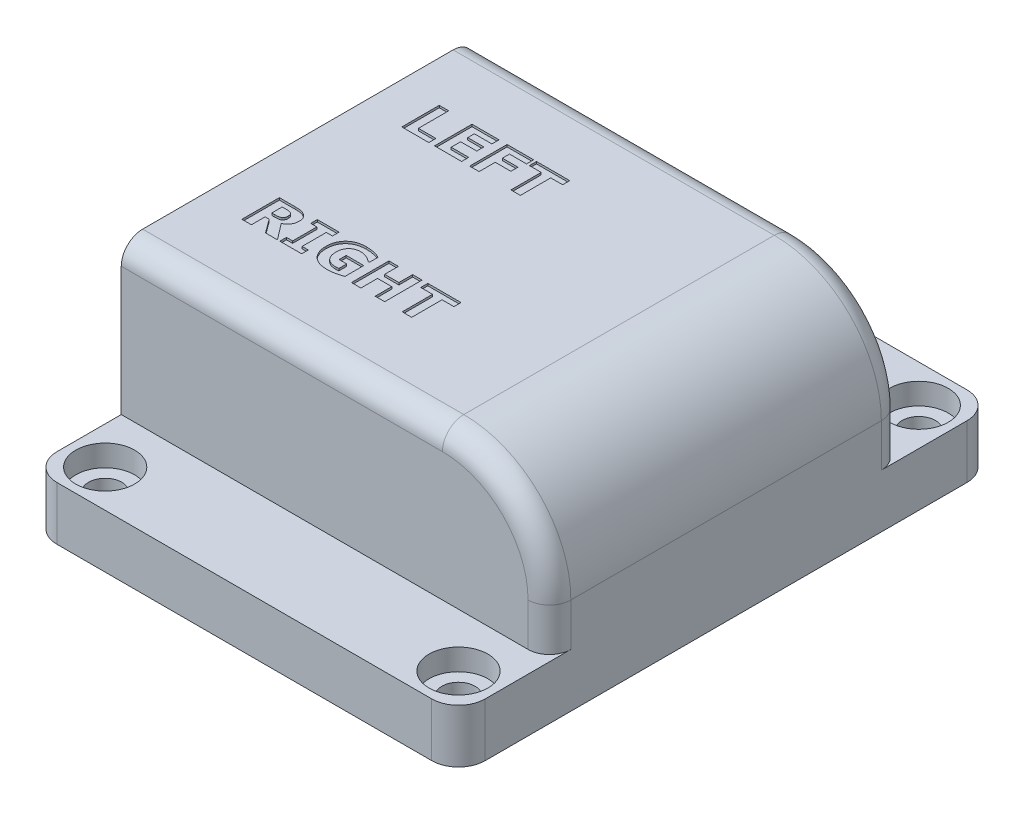
from build123d import *

# Parameters (mm, degrees)
SKETCH1_W               = 40
SKETCH1_H               = 50
BOSS_EXTRUDE1_DEPTH     = 5
SKETCH2_W               = 40
SKETCH2_H               = 33
BOSS_EXTRUDE2_DEPTH     = 14
CUT_EXTRUDE2_DEPTH      = 23
SKETCH6_W               = 14
SKETCH6_H               = 30
CUT_EXTRUDE3_DEPTH      = 17.25
FILLET1_R               = 10
SKETCH7_W               = 5
SKETCH7_H               = 5
CUT_EXTRUDE4_DEPTH      = 0.6
SKETCH8_R               = 1.55
CUT_EXTRUDE5_DEPTH      = 15
CUT_EXTRUDE5_DEPTH_BACK = 6
SKETCH9_R               = 2.75
CUT_EXTRUDE6_DEPTH      = 2
FILLET2_R               = 2.5
FILLET3_R               = 2
CUT_EXTRUDE8_DEPTH      = 0.2


with BuildPart() as part:
    # Sketch1 → Boss-Extrude1 (new body)
    with BuildSketch(Plane(origin=(0, 0, 0), x_dir=(1, 0, 0), z_dir=(0, 1, 0))):
        Rectangle(SKETCH1_W, SKETCH1_H)
    extrude(amount=BOSS_EXTRUDE1_DEPTH)

    # Sketch2 → Boss-Extrude2 (add)
    with BuildSketch(Plane(origin=(0, 5, 0), x_dir=(1, 0, 0), z_dir=(0, 1, 0))):
        Rectangle(SKETCH2_W, SKETCH2_H)
    extrude(amount=BOSS_EXTRUDE2_DEPTH)

    # Sketch5 → Cut-Extrude2 (cut)
    with BuildSketch(Plane.ZY.offset(20)):
        Polygon((-13.5, 5), (-13.2, 7), (-13.2, 7.5), (-14.8, 7.5), (-14.8, 17.35), (-2, 17.35), (-2, 7.5), (-3.6, 7.5), (-3.6, 7), (-2, 5), align=None)
        Polygon((2, 17.35), (14.8, 17.35), (14.8, 7.5), (13.2, 7.5), (13.2, 7), (14.8, 5), (2, 5), (3.6, 7), (3.6, 7.5), (2, 7.5), align=None)
    extrude(amount=-CUT_EXTRUDE2_DEPTH, mode=Mode.SUBTRACT)

    # Sketch6 → Cut-Extrude3 (cut)
    with BuildSketch(Plane.XZ):
        with Locations((10, 0)):
            Rectangle(SKETCH6_W, SKETCH6_H)
    extrude(amount=-CUT_EXTRUDE3_DEPTH, mode=Mode.SUBTRACT)

    # Fillet1
    fillet1_edges = [part.edges().sort_by_distance(p)[0] for p in [
        (20, 19, 0),
        (17, 17.25, 0),
    ]]
    fillet(fillet1_edges, radius=FILLET1_R)

    # Sketch7 → Cut-Extrude4 (cut)
    with BuildSketch(Plane(origin=(0, 5, 0), x_dir=(1, 0, 0), z_dir=(0, 1, 0))):
        with Locations((-14.5, 7.75)):
            Rectangle(SKETCH7_W, SKETCH7_H)
        with Locations((-14.5, -8.4)):
            Rectangle(SKETCH7_W, SKETCH7_H)
    extrude(amount=-CUT_EXTRUDE4_DEPTH, mode=Mode.SUBTRACT)

    # Sketch8 → Cut-Extrude5 (cut, two sides)
    with BuildSketch(Plane(origin=(0, 5, 0), x_dir=(1, 0, 0), z_dir=(0, 1, 0))) as cut_extrude5_sk:
        with Locations((-16.5, 21.5)):
            Circle(SKETCH8_R)
        with Locations((16.5, 21.5)):
            Circle(SKETCH8_R)
        with Locations((16.5, -21.5)):
            Circle(SKETCH8_R)
        with Locations((-16.5, -21.5)):
            Circle(SKETCH8_R)
    extrude(amount=CUT_EXTRUDE5_DEPTH, mode=Mode.SUBTRACT)
    extrude(cut_extrude5_sk.sketch, amount=-CUT_EXTRUDE5_DEPTH_BACK, mode=Mode.SUBTRACT)

    # Sketch9 → Cut-Extrude6 (cut)
    with BuildSketch(Plane(origin=(0, 5, 0), x_dir=(1, 0, 0), z_dir=(0, 1, 0))):
        with Locations((-16.5, 21.5)):
            Circle(SKETCH9_R)
        with Locations((16.5, 21.5)):
            Circle(SKETCH9_R)
        with Locations((16.5, -21.5)):
            Circle(SKETCH9_R)
        with Locations((-16.5, -21.5)):
            Circle(SKETCH9_R)
    extrude(amount=-CUT_EXTRUDE6_DEPTH, mode=Mode.SUBTRACT)

    # Fillet2
    fillet2_edges = [part.edges().sort_by_distance(p)[0] for p in [
        (20, 2.5, 25),
        (-20, 2.5, 25),
        (-20, 2.5, -25),
        (20, 2.5, -25),
    ]]
    fillet(fillet2_edges, radius=FILLET2_R)

    # Fillet3
    fillet3_edges = [part.edges().sort_by_distance(p)[0] for p in [
        (-5, 19, -16.5),
        (20, 7, -16.5),
        (17.071067812, 16.071067812, -16.5),
        (20, 7, 16.5),
        (17.071067812, 16.071067812, 16.5),
        (-5, 19, 16.5),
    ]]
    fillet(fillet3_edges, radius=FILLET3_R)

    # Sketch11 → Cut-Extrude8 (cut)
    with BuildSketch(Plane(origin=(0, 19, 0), x_dir=(1, 0, 0), z_dir=(0, 1, 0))):
        Polygon((-13.636505327, 5.868384171), (-16.161821783, 5.868384171), (-16.161821783, 9.368384171), (-15.275745834, 9.368384171), (-15.275745834, 6.532941133), (-13.636505327, 6.532941133), align=None)
        Polygon((-10.579543302, 5.868384171), (-13.104859758, 5.868384171), (-13.104859758, 9.368384171), (-10.579543302, 9.368384171), (-10.579543302, 8.703827209), (-12.218783808, 8.703827209), (-12.218783808, 8.083574045), (-10.712454694, 8.083574045), (-10.712454694, 7.419017083), (-12.218783808, 7.419017083), (-12.218783808, 6.532941133), (-10.579543302, 6.532941133), align=None)
        Polygon((-7.345366087, 8.703827209), (-8.940302796, 8.703827209), (-8.940302796, 8.039270247), (-7.478277479, 8.039270247), (-7.478277479, 7.374713285), (-8.940302796, 7.374713285), (-8.940302796, 5.868384171), (-9.826378745, 5.868384171), (-9.826378745, 9.368384171), (-7.345366087, 9.368384171), align=None)
        Polygon((-3.978277479, 8.703827209), (-5.085872416, 8.703827209), (-5.085872416, 5.868384171), (-5.971948365, 5.868384171), (-5.971948365, 8.703827209), (-7.079543302, 8.703827209), (-7.079543302, 9.368384171), (-3.978277479, 9.368384171), align=None)
        with BuildLine():
            Line((-12.839036973, -9.069320992), (-13.955631118, -9.069320992))
            Line((-13.955631118, -9.069320992), (-14.895010074, -7.784510866))
            Line((-14.895010074, -7.784510866), (-15.275745834, -7.784510866))
            Line((-15.275745834, -7.784510866), (-15.275745834, -9.069320992))
            Line((-15.275745834, -9.069320992), (-16.161821783, -9.069320992))
            Line((-16.161821783, -9.069320992), (-16.161821783, -5.569320992))
            Line((-16.161821783, -5.569320992), (-14.679721308, -5.569320992))
            add(Edge.make_bspline(
                [(-14.679721308, -5.569320992), (-14.630793363, -5.56962327), (-14.536575844, -5.570205349), (-14.400573635, -5.577315294), (-14.275192532, -5.588328147), (-14.158660197, -5.602794166), (-14.04914179, -5.625615007), (-13.944223236, -5.65839359), (-13.843023823, -5.701776649), (-13.779235539, -5.738509409), (-13.747264821, -5.756919885)],
                knots=[0, 0, 0, 0, 0.000146771, 0.000282628, 0.000408413, 0.000524331, 0.000634711, 0.000743526, 0.000853602, 0.000964208, 0.000964208, 0.000964208, 0.000964208], degree=3))
            add(Edge.make_bspline(
                [(-13.747264821, -5.756919885), (-13.716242959, -5.77716063), (-13.654787107, -5.817258553), (-13.573066481, -5.890316551), (-13.50026001, -5.970908608), (-13.437887545, -6.061033235), (-13.387384264, -6.161627496), (-13.351366684, -6.27406869), (-13.32980319, -6.398265702), (-13.327549358, -6.485072978), (-13.326378745, -6.5301596)],
                knots=[0, 0, 0, 0, 0.000110986, 0.00021987, 0.000327718, 0.000436209, 0.000547658, 0.000664121, 0.000789195, 0.000924361, 0.000924361, 0.000924361, 0.000924361], degree=3))
            add(Edge.make_bspline(
                [(-13.326378745, -6.5301596), (-13.326861478, -6.561794377), (-13.327804031, -6.623562332), (-13.336584182, -6.713912611), (-13.349257951, -6.799812924), (-13.368051492, -6.881281237), (-13.39227768, -6.958385551), (-13.421883149, -7.031241836), (-13.457391278, -7.099195114), (-13.497809531, -7.162992115), (-13.544212254, -7.222342151), (-13.593813895, -7.280176451), (-13.648720358, -7.334683455), (-13.707931064, -7.386873172), (-13.771580392, -7.436782622), (-13.840318687, -7.483818678), (-13.913614955, -7.528157724), (-13.964941405, -7.554957231), (-13.990935707, -7.568529853)],
                knots=[0, 0, 0, 0, 9.4878e-05, 0.000185253, 0.000272093, 0.000355215, 0.000435784, 0.000514328, 0.000590805, 0.000665507, 0.000740551, 0.000816613, 0.000893953, 0.000972425, 0.001053296, 0.001136438, 0.001222154, 0.00131011, 0.00131011, 0.00131011, 0.00131011], degree=3))
            Line((-13.990935707, -7.568529853), (-12.839036973, -9.069320992))
        make_face()
        with BuildLine():
            add(Edge.make_bspline(
                [(-14.256758492, -6.631919885), (-14.257432132, -6.609961626), (-14.258736751, -6.567435755), (-14.268473716, -6.506302486), (-14.284428429, -6.449916465), (-14.30707141, -6.398223613), (-14.338170802, -6.351347094), (-14.378564696, -6.309978079), (-14.428136588, -6.273622682), (-14.466167417, -6.255200736), (-14.485892194, -6.24564615)],
                knots=[0, 0, 0, 0, 6.5854e-05, 0.000127538, 0.000185161, 0.00024125, 0.000296161, 0.00035295, 0.000413872, 0.000479515, 0.000479515, 0.000479515, 0.000479515], degree=3))
            add(Edge.make_bspline(
                [(-14.485892194, -6.24564615), (-14.501025811, -6.239607726), (-14.531976418, -6.227258205), (-14.581562932, -6.213431801), (-14.634913415, -6.204001055), (-14.713915753, -6.195876897), (-14.823634103, -6.190523307), (-14.914387464, -6.189904567), (-14.962850264, -6.189574157)],
                knots=[0, 0, 0, 0, 4.8856e-05, 9.9918e-05, 0.000154095, 0.0002112, 0.000338071, 0.000483457, 0.000483457, 0.000483457, 0.000483457], degree=3))
            Line((-14.962850264, -6.189574157), (-15.275745834, -6.189574157))
            Line((-15.275745834, -6.189574157), (-15.275745834, -7.164257701))
            Line((-15.275745834, -7.164257701), (-15.010615296, -7.164257701))
            add(Edge.make_bspline(
                [(-15.010615296, -7.164257701), (-14.977612091, -7.164033033), (-14.914115918, -7.163600785), (-14.823406858, -7.159221592), (-14.740893914, -7.153441999), (-14.666320438, -7.144068583), (-14.598107527, -7.129914619), (-14.535923523, -7.108674045), (-14.479741502, -7.079200303), (-14.446379786, -7.054622044), (-14.429820201, -7.042422258)],
                knots=[0, 0, 0, 0, 9.9001e-05, 0.000190472, 0.000272394, 0.000347096, 0.0004158, 0.00048104, 0.000543588, 0.000605233, 0.000605233, 0.000605233, 0.000605233], degree=3))
            add(Edge.make_bspline(
                [(-14.429820201, -7.042422258), (-14.415491815, -7.029768514), (-14.387684576, -7.005211268), (-14.351017461, -6.964671042), (-14.321425474, -6.921652855), (-14.296646229, -6.875985958), (-14.278822493, -6.82501849), (-14.265536493, -6.767502759), (-14.258368543, -6.702246148), (-14.257313549, -6.656164522), (-14.256758492, -6.631919885)],
                knots=[0, 0, 0, 0, 5.7323e-05, 0.000111247, 0.000163478, 0.000213646, 0.000266638, 0.000324906, 0.000390421, 0.00046316, 0.00046316, 0.00046316, 0.00046316], degree=3))
        make_face(mode=Mode.SUBTRACT)
        Polygon((-10.579543302, -9.069320992), (-12.617517986, -9.069320992), (-12.617517986, -8.449067828), (-12.041568618, -8.449067828), (-12.041568618, -6.189574157), (-12.617517986, -6.189574157), (-12.617517986, -5.569320992), (-10.579543302, -5.569320992), (-10.579543302, -6.189574157), (-11.155492669, -6.189574157), (-11.155492669, -8.449067828), (-10.579543302, -8.449067828), align=None)
        with BuildLine():
            add(Edge.make_bspline(
                [(-6.725112922, -8.880337606), (-6.767674975, -8.89616153), (-6.858331708, -8.929866325), (-7.00584711, -8.975782434), (-7.17243407, -9.021598519), (-7.354577062, -9.067853051), (-7.546318099, -9.107689569), (-7.741325475, -9.136854812), (-7.936202154, -9.154857709), (-8.066188174, -9.156906169), (-8.131066245, -9.157928587)],
                knots=[0, 0, 0, 0, 0.000136206, 0.000290117, 0.000463275, 0.000654507, 0.000853807, 0.001050489, 0.001245779, 0.001440379, 0.001440379, 0.001440379, 0.001440379], degree=3))
            add(Edge.make_bspline(
                [(-8.131066245, -9.157928587), (-8.204041145, -9.156528005), (-8.346212906, -9.15379935), (-8.553541416, -9.130821886), (-8.7484377, -9.092004642), (-8.931761338, -9.039351458), (-9.102112916, -8.969367232), (-9.261263914, -8.885885358), (-9.407388112, -8.78519856), (-9.541052679, -8.670518715), (-9.660649148, -8.541875255), (-9.764848527, -8.401024944), (-9.852709834, -8.248105219), (-9.923934105, -8.083531454), (-9.980517234, -7.907666998), (-10.018992171, -7.719621972), (-10.0442381, -7.520298574), (-10.046657369, -7.383319961), (-10.047897732, -7.313090771)],
                knots=[0, 0, 0, 0, 0.000218882, 0.000426433, 0.00062478, 0.000814483, 0.000997667, 0.001176349, 0.001352615, 0.001528839, 0.001703703, 0.001878431, 0.002053334, 0.002231586, 0.002415481, 0.002606508, 0.002806654, 0.003017235, 0.003017235, 0.003017235, 0.003017235], degree=3))
            add(Edge.make_bspline(
                [(-10.047897732, -7.313090771), (-10.046324929, -7.246097298), (-10.043244552, -7.114888854), (-10.018447182, -6.923035087), (-9.978643953, -6.741012617), (-9.922670491, -6.568866098), (-9.849383126, -6.407278313), (-9.760287453, -6.2555389), (-9.655349551, -6.113364771), (-9.533905759, -5.982999932), (-9.399270853, -5.864030292), (-9.250117296, -5.761259623), (-9.08817886, -5.674366742), (-8.913846006, -5.602764778), (-8.726389522, -5.548494826), (-8.526948037, -5.509460795), (-8.314918146, -5.484380863), (-8.169213169, -5.481957876), (-8.094377163, -5.480713397)],
                knots=[0, 0, 0, 0, 0.000200923, 0.000393514, 0.000579273, 0.000759217, 0.000935501, 0.001110502, 0.001286197, 0.001464504, 0.001644043, 0.001824161, 0.00200659, 0.002194404, 0.002388483, 0.002591038, 0.002803559, 0.003027976, 0.003027976, 0.003027976, 0.003027976], degree=3))
            add(Edge.make_bspline(
                [(-8.094377163, -5.480713397), (-8.036897102, -5.481236493), (-7.922966036, -5.48227332), (-7.754394334, -5.494835723), (-7.589805141, -5.5129562), (-7.427206316, -5.540309312), (-7.261764379, -5.578623531), (-7.090278524, -5.632850372), (-6.909267454, -5.70062172), (-6.788014823, -5.755921856), (-6.725112922, -5.784609758)],
                knots=[0, 0, 0, 0, 0.000172404, 0.000341722, 0.000506846, 0.000669018, 0.000836092, 0.001015853, 0.001208198, 0.001415546, 0.001415546, 0.001415546, 0.001415546], degree=3))
            Line((-6.725112922, -5.784609758), (-6.725112922, -6.588308334))
            Line((-6.725112922, -6.588308334), (-6.828257701, -6.588308334))
            add(Edge.make_bspline(
                [(-6.828257701, -6.588308334), (-6.840741957, -6.580036961), (-6.868325071, -6.561761925), (-6.912996802, -6.530931039), (-6.966530988, -6.496779164), (-7.046099868, -6.444894169), (-7.147364039, -6.380544013), (-7.232432955, -6.336675045), (-7.273372416, -6.315563081)],
                knots=[0, 0, 0, 0, 4.4927e-05, 9.9263e-05, 0.000162818, 0.000235398, 0.000384284, 0.000522408, 0.000522408, 0.000522408, 0.000522408], degree=3))
            add(Edge.make_bspline(
                [(-7.273372416, -6.315563081), (-7.297469542, -6.303961682), (-7.346861671, -6.280182176), (-7.425372245, -6.249323538), (-7.509561423, -6.221032844), (-7.59876811, -6.194740149), (-7.692441675, -6.172438541), (-7.789785091, -6.15636252), (-7.890003029, -6.147614842), (-7.957758277, -6.146056281), (-7.991924631, -6.145270359)],
                knots=[0, 0, 0, 0, 8.0211e-05, 0.000164409, 0.000252849, 0.000346607, 0.000443324, 0.000541537, 0.000642316, 0.000744827, 0.000744827, 0.000744827, 0.000744827], degree=3))
            add(Edge.make_bspline(
                [(-7.991924631, -6.145270359), (-8.03166283, -6.145893866), (-8.109548447, -6.147115918), (-8.223366041, -6.161825127), (-8.332039178, -6.183247415), (-8.43483672, -6.215528223), (-8.532570425, -6.256139962), (-8.624262731, -6.307707803), (-8.712574892, -6.366551143), (-8.765474262, -6.41410159), (-8.792161973, -6.438090771)],
                knots=[0, 0, 0, 0, 0.000119139, 0.000233508, 0.000343748, 0.000451035, 0.000556204, 0.000660623, 0.000766226, 0.000873748, 0.000873748, 0.000873748, 0.000873748], degree=3))
            add(Edge.make_bspline(
                [(-8.792161973, -6.438090771), (-8.816609307, -6.463120066), (-8.866018846, -6.513705783), (-8.928801139, -6.601961581), (-8.984901241, -6.698723589), (-9.032766094, -6.805063986), (-9.071126318, -6.920459498), (-9.097421029, -7.044937978), (-9.1146593, -7.177852658), (-9.116546606, -7.269422041), (-9.117517986, -7.316552005)],
                knots=[0, 0, 0, 0, 0.000104825, 0.000211857, 0.000323823, 0.000440009, 0.000561066, 0.000687885, 0.000821144, 0.00096247, 0.00096247, 0.00096247, 0.00096247], degree=3))
            add(Edge.make_bspline(
                [(-9.117517986, -7.316552005), (-9.116652035, -7.364588476), (-9.114970025, -7.457893902), (-9.100147647, -7.593305476), (-9.07645576, -7.720193409), (-9.041475638, -7.838220253), (-8.99818289, -7.9481873), (-8.944832651, -8.049575917), (-8.880358981, -8.141198844), (-8.807776697, -8.225106463), (-8.72438708, -8.298842155), (-8.632141146, -8.363511925), (-8.530274589, -8.41775009), (-8.419035864, -8.461201029), (-8.299013075, -8.495761301), (-8.169535752, -8.520601522), (-8.030790551, -8.53504318), (-7.935195103, -8.536781203), (-7.886010865, -8.537675423)],
                knots=[0, 0, 0, 0, 0.000144069, 0.000279838, 0.000408135, 0.000530801, 0.000648551, 0.000762201, 0.000873582, 0.000983962, 0.001094282, 0.001206627, 0.001321214, 0.001439606, 0.001564266, 0.001695414, 0.001834624, 0.001982152, 0.001982152, 0.001982152, 0.001982152], degree=3))
            add(Edge.make_bspline(
                [(-7.886010865, -8.537675423), (-7.867781864, -8.537459626), (-7.829474192, -8.537006136), (-7.771056684, -8.536012552), (-7.712417702, -8.53258895), (-7.673943981, -8.52900873), (-7.655492669, -8.52729172)],
                knots=[0, 0, 0, 0, 5.4692e-05, 0.000114933, 0.000175258, 0.000230849, 0.000230849, 0.000230849, 0.000230849], degree=3))
            Line((-7.655492669, -8.52729172), (-7.655492669, -7.784510866))
            Line((-7.655492669, -7.784510866), (-8.364353429, -7.784510866))
            Line((-8.364353429, -7.784510866), (-8.364353429, -7.119953904))
            Line((-8.364353429, -7.119953904), (-6.725112922, -7.119953904))
            Line((-6.725112922, -7.119953904), (-6.725112922, -8.880337606))
        make_face()
        Polygon((-2.826378745, -9.069320992), (-3.712454694, -9.069320992), (-3.712454694, -7.518688081), (-5.041568618, -7.518688081), (-5.041568618, -9.069320992), (-5.927644568, -9.069320992), (-5.927644568, -5.569320992), (-5.041568618, -5.569320992), (-5.041568618, -6.854131119), (-3.712454694, -6.854131119), (-3.712454694, -5.569320992), (-2.826378745, -5.569320992), align=None)
        Polygon((0.806532647, -6.233877954), (-0.301062289, -6.233877954), (-0.301062289, -9.069320992), (-1.187138239, -9.069320992), (-1.187138239, -6.233877954), (-2.294733175, -6.233877954), (-2.294733175, -5.569320992), (0.806532647, -5.569320992), align=None)
    extrude(amount=-CUT_EXTRUDE8_DEPTH, mode=Mode.SUBTRACT)


solid = part.part
